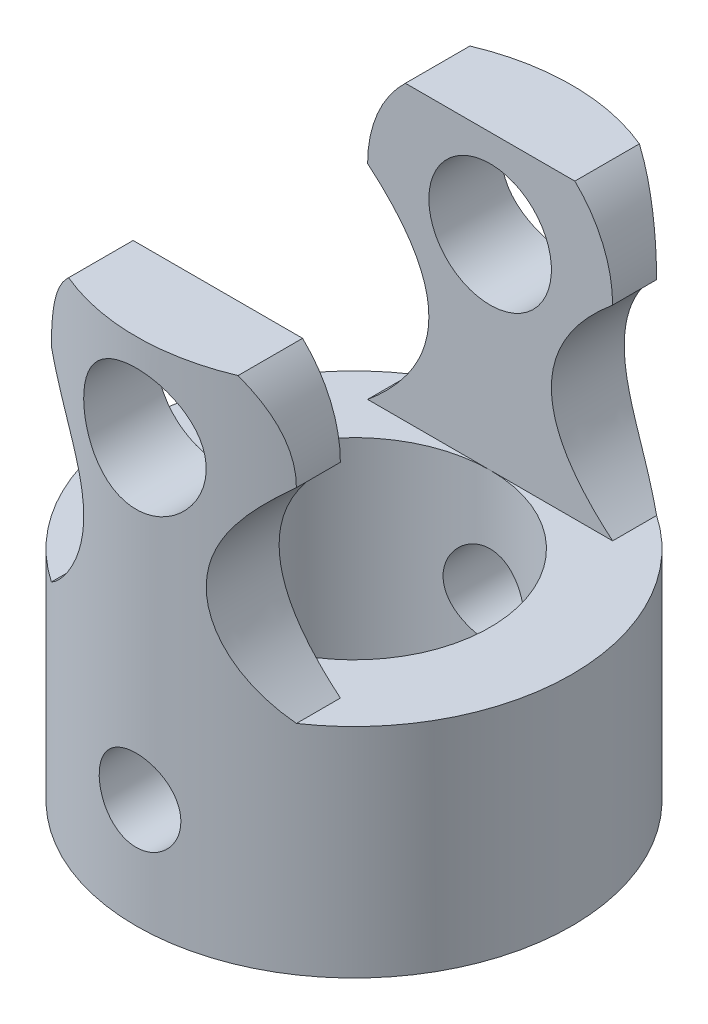
from build123d import *
from build123d.topology import SkipClean

# Parameters (mm, degrees)
SKETCH2_R                            = 8
SKETCH2_R_2                          = 5
BOSS_EXTRUDE1_DEPTH                  = 8
BOSS_EXTRUDE2_REACH                  = 15.856
BOSS_EXTRUDE2_END_RADIUS             = 8
SKETCH3_R                            = 2.25
BOSS_EXTRUDE2_DIRECTION_2_REACH      = 15.856
BOSS_EXTRUDE2_DIRECTION_2_END_RADIUS = 8
SKETCH4_R                            = 5
CUT_EXTRUDE1_DEPTH                   = 23.978250708
CUT_EXTRUDE2_DEPTH                   = 23.978250708
CUT_EXTRUDE2_DEPTH_BACK              = 23.978250708
SKETCH5_W                            = 10
SKETCH5_H                            = 12
CUT_EXTRUDE3_DEPTH                   = 23.978250708
CUT_EXTRUDE3_DEPTH_BACK              = 23.978250708
SKETCH6_R                            = 1.5
CUT_EXTRUDE4_DEPTH                   = 23.978250752
CUT_EXTRUDE4_DEPTH_BACK              = 23.978250752


with BuildPart() as part:
    # Sketch2 → Boss-Extrude1 (new body)
    with BuildSketch(Plane(origin=(0, 0, 0), x_dir=(1, 0, 0), z_dir=(0, 1, 0))):
        with Locations(Location((0, 0, 0), (0, 0, 270))):
            Circle(SKETCH2_R)
        with Locations(Location((0, 0, 0), (0, 0, 270))):
            Circle(SKETCH2_R_2, mode=Mode.SUBTRACT)
    extrude(amount=BOSS_EXTRUDE1_DEPTH)

    # Boss-Extrude2: up to this cylinder (the profile starts inside it)
    boss_extrude2_end = Plane(origin=(0, 11.750122, 0), z_dir=(0, -1, 0)) * Cylinder(BOSS_EXTRUDE2_END_RADIUS, 48.712, mode=Mode.PRIVATE)
    # Sketch3 → Boss-Extrude2 (add, up to the surface)
    with BuildSketch(Plane.XY, mode=Mode.PRIVATE) as boss_extrude2_sk1:
        with BuildLine():
            Line((0, 8), (-4.5, 8))
            add(Edge.make_bspline(
                [(-4.5, 15.5), (0, 11.75), (-4.5, 8)],
                knots=[0, 0, 0, 1, 1, 1], degree=2))
            ThreePointArc((-4.5, 15.5), (0, 20), (4.5, 15.5))
            add(Edge.make_bspline(
                [(4.5, 15.5), (0, 11.75), (4.5, 8)],
                knots=[0, 0, 0, 1, 1, 1], degree=2))
            Line((4.5, 8), (0, 8))
        make_face()
        with Locations(Location((0, 15.5, 0), (0, 0, 180))):
            Circle(SKETCH3_R, mode=Mode.SUBTRACT)
    boss_extrude2_tool1 = extrude(boss_extrude2_sk1.sketch, amount=BOSS_EXTRUDE2_REACH, mode=Mode.PRIVATE) & boss_extrude2_end
    add(boss_extrude2_tool1.solids().sort_by_distance((2.1, 11.750122, 0))[0])

    # Boss-Extrude2 direction 2: up to this cylinder (the profile starts inside it)
    boss_extrude2_direction_2_end = Plane(origin=(0, 11.750122, 0), z_dir=(0, -1, 0)) * Cylinder(BOSS_EXTRUDE2_DIRECTION_2_END_RADIUS, 48.712, mode=Mode.PRIVATE)
    # Sketch3 → Boss-Extrude2 direction 2 (add, up to the surface)
    with BuildSketch(Plane.XY, mode=Mode.PRIVATE) as boss_extrude2_direction_2_sk1:
        with BuildLine():
            Line((0, 8), (-4.5, 8))
            add(Edge.make_bspline(
                [(-4.5, 15.5), (0, 11.75), (-4.5, 8)],
                knots=[0, 0, 0, 1, 1, 1], degree=2))
            ThreePointArc((-4.5, 15.5), (0, 20), (4.5, 15.5))
            add(Edge.make_bspline(
                [(4.5, 15.5), (0, 11.75), (4.5, 8)],
                knots=[0, 0, 0, 1, 1, 1], degree=2))
            Line((4.5, 8), (0, 8))
        make_face()
        with Locations(Location((0, 15.5, 0), (0, 0, 180))):
            Circle(SKETCH3_R, mode=Mode.SUBTRACT)
    boss_extrude2_direction_2_tool1 = extrude(boss_extrude2_direction_2_sk1.sketch, amount=-BOSS_EXTRUDE2_DIRECTION_2_REACH, mode=Mode.PRIVATE) & boss_extrude2_direction_2_end
    add(boss_extrude2_direction_2_tool1.solids().sort_by_distance((2.1, 11.750122, 0))[0])

    # Sketch4 → Cut-Extrude1 (cut, through all)
    with BuildSketch(Plane.XZ):
        with Locations(Location((0, 0, 0), (0, 0, 90))):
            Circle(SKETCH4_R)
    extrude(amount=-CUT_EXTRUDE1_DEPTH, mode=Mode.SUBTRACT)

    # Sketch5 → Cut-Extrude2 (cut, two sides: drawn at the far end of the back side and taken through both)
    with BuildSketch(Plane(origin=(0, 0, 0), x_dir=(0, 0, -1), z_dir=(1, 0, 0)).offset(-CUT_EXTRUDE2_DEPTH_BACK)):
        with Locations((0, 14)):
            Rectangle(SKETCH5_W, SKETCH5_H)
    extrude(amount=CUT_EXTRUDE2_DEPTH + CUT_EXTRUDE2_DEPTH_BACK, mode=Mode.SUBTRACT)

    # Sketch6 → Cut-Extrude3 (cut, two sides: drawn at the far end of the back side and taken through both)
    with SkipClean():  # the faces are left unmerged after this step: merging them gives an invalid solid
        with BuildSketch(Plane.XY.offset(-CUT_EXTRUDE3_DEPTH_BACK)):
            with Locations((0, 4)):
                Circle(SKETCH6_R)
        extrude(amount=CUT_EXTRUDE3_DEPTH + CUT_EXTRUDE3_DEPTH_BACK, mode=Mode.SUBTRACT)

    # Sketch7 → Cut-Extrude4 (cut, two sides: drawn at the far end of the back side and taken through both)
    with SkipClean():  # the faces are left unmerged after this step: merging them gives an invalid solid
        with BuildSketch(Plane.XY.offset(-CUT_EXTRUDE4_DEPTH_BACK)):
            with BuildLine():
                Line((-3.112474899, 18.75), (3.112474899, 18.75))
                ThreePointArc((3.112474899, 18.75), (0, 20), (-3.112474899, 18.75))
            make_face()
        extrude(amount=CUT_EXTRUDE4_DEPTH + CUT_EXTRUDE4_DEPTH_BACK, mode=Mode.SUBTRACT)


solid = part.part
